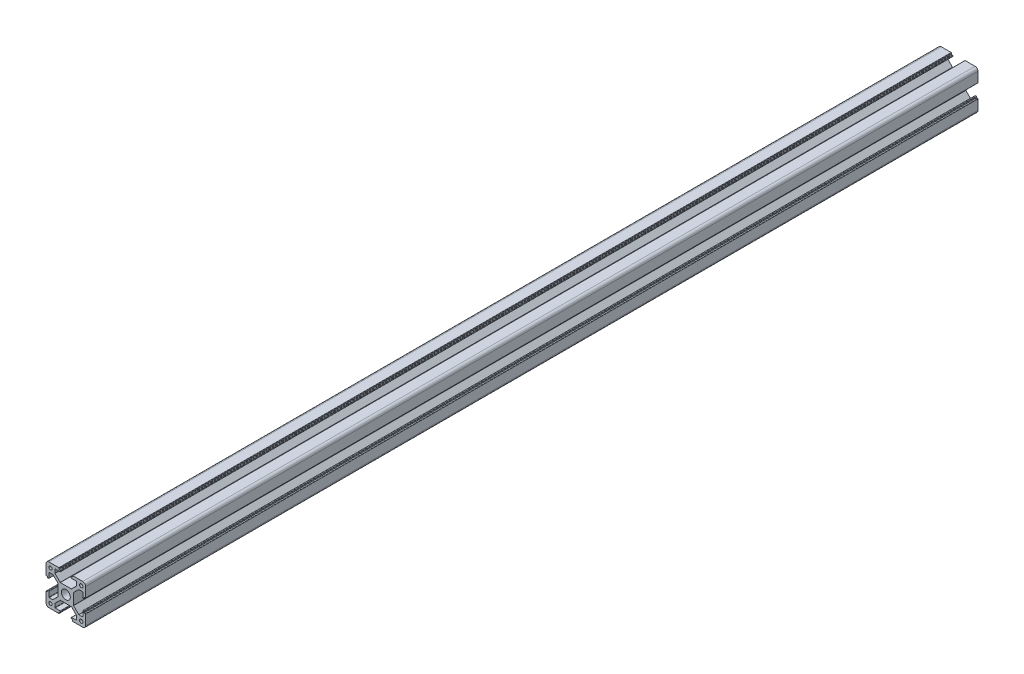
from build123d import *

# Parameters (mm, degrees)
CROQUIS1_R              = 1.25
CROQUIS1_R_2            = 3.4
SALIENTE_EXTRUIR1_DEPTH = 675


with BuildPart() as part:
    # Croquis1 → Saliente-Extruir1 (new body)
    with BuildSketch(Plane.XY):
        with BuildLine():
            Line((-4.161522369, 5.8), (4.161522369, 5.8))
            ThreePointArc((4.161522369, 5.8), (4.238059055, 5.815224093), (4.302943725, 5.858578644))
            Line((4.302943725, 5.858578644), (8.191421356, 9.747056275))
            ThreePointArc((8.191421356, 9.747056275), (8.234775907, 9.811940945), (8.25, 9.888477631))
            Line((8.25, 9.888477631), (8.25, 12.6))
            ThreePointArc((8.25, 12.6), (8.191421356, 12.741421356), (8.05, 12.8))
            Line((8.05, 12.8), (4.3, 12.8))
            ThreePointArc((4.3, 12.8), (4.158578644, 12.858578644), (4.1, 13))
            Line((4.1, 13), (4.1, 13.7))
            ThreePointArc((4.1, 13.7), (4.158578644, 13.841421356), (4.3, 13.9))
            Line((4.3, 13.9), (4.9, 13.9))
            ThreePointArc((4.9, 13.9), (5.041421356, 13.958578644), (5.1, 14.1))
            Line((5.1, 14.1), (5.1, 14.8))
            ThreePointArc((5.1, 14.8), (5.158578644, 14.941421356), (5.3, 15))
            Line((5.3, 15), (12.8, 15))
            ThreePointArc((12.8, 15), (14.355634919, 14.355634919), (15, 12.8))
            Line((15, 12.8), (15, 5.3))
            ThreePointArc((15, 5.3), (14.941421356, 5.158578644), (14.8, 5.1))
            Line((14.8, 5.1), (13.9, 5.1))
            Line((13.9, 5.1), (13.9, 4.3))
            ThreePointArc((13.9, 4.3), (13.841421356, 4.158578644), (13.7, 4.1))
            Line((13.7, 4.1), (13, 4.1))
            ThreePointArc((13, 4.1), (12.858578644, 4.158578644), (12.8, 4.3))
            Line((12.8, 4.3), (12.8, 8.05))
            ThreePointArc((12.8, 8.05), (12.741421356, 8.191421356), (12.6, 8.25))
            Line((12.6, 8.25), (9.888477631, 8.25))
            ThreePointArc((9.888477631, 8.25), (9.811940945, 8.234775907), (9.747056275, 8.191421356))
            Line((9.747056275, 8.191421356), (5.858578644, 4.302943725))
            ThreePointArc((5.858578644, 4.302943725), (5.815224093, 4.238059055), (5.8, 4.161522369))
            Line((5.8, 4.161522369), (5.8, -4.161522369))
            ThreePointArc((5.8, -4.161522369), (5.815224093, -4.238059055), (5.858578644, -4.302943725))
            Line((5.858578644, -4.302943725), (9.747056275, -8.191421356))
            ThreePointArc((9.747056275, -8.191421356), (9.811940945, -8.234775907), (9.888477631, -8.25))
            Line((9.888477631, -8.25), (12.6, -8.25))
            ThreePointArc((12.6, -8.25), (12.741421356, -8.191421356), (12.8, -8.05))
            Line((12.8, -8.05), (12.8, -4.3))
            ThreePointArc((12.8, -4.3), (12.858578644, -4.158578644), (13, -4.1))
            Line((13, -4.1), (13.7, -4.1))
            ThreePointArc((13.7, -4.1), (13.841421356, -4.158578644), (13.9, -4.3))
            Line((13.9, -4.3), (13.9, -5.1))
            Line((13.9, -5.1), (14.8, -5.1))
            ThreePointArc((14.8, -5.1), (14.941421356, -5.158578644), (15, -5.3))
            Line((15, -5.3), (15, -12.8))
            ThreePointArc((15, -12.8), (14.355634919, -14.355634919), (12.8, -15))
            Line((12.8, -15), (5.3, -15))
            ThreePointArc((5.3, -15), (5.158578644, -14.941421356), (5.1, -14.8))
            Line((5.1, -14.8), (5.1, -14.1))
            ThreePointArc((5.1, -14.1), (5.041421356, -13.958578644), (4.9, -13.9))
            Line((4.9, -13.9), (4.3, -13.9))
            ThreePointArc((4.3, -13.9), (4.158578644, -13.841421356), (4.1, -13.7))
            Line((4.1, -13.7), (4.1, -13))
            ThreePointArc((4.1, -13), (4.158578644, -12.858578644), (4.3, -12.8))
            Line((4.3, -12.8), (8.05, -12.8))
            ThreePointArc((8.05, -12.8), (8.191421356, -12.741421356), (8.25, -12.6))
            Line((8.25, -12.6), (8.25, -9.888477631))
            ThreePointArc((8.25, -9.888477631), (8.234775907, -9.811940945), (8.191421356, -9.747056275))
            Line((8.191421356, -9.747056275), (4.302943725, -5.858578644))
            ThreePointArc((4.302943725, -5.858578644), (4.238059055, -5.815224093), (4.161522369, -5.8))
            Line((4.161522369, -5.8), (-4.161522369, -5.8))
            ThreePointArc((-4.161522369, -5.8), (-4.238059055, -5.815224093), (-4.302943725, -5.858578644))
            Line((-4.302943725, -5.858578644), (-8.191421356, -9.747056275))
            ThreePointArc((-8.191421356, -9.747056275), (-8.234775907, -9.811940945), (-8.25, -9.888477631))
            Line((-8.25, -9.888477631), (-8.25, -12.6))
            ThreePointArc((-8.25, -12.6), (-8.191421356, -12.741421356), (-8.05, -12.8))
            Line((-8.05, -12.8), (-4.3, -12.8))
            ThreePointArc((-4.3, -12.8), (-4.158578644, -12.858578644), (-4.1, -13))
            Line((-4.1, -13), (-4.1, -13.7))
            ThreePointArc((-4.1, -13.7), (-4.158578644, -13.841421356), (-4.3, -13.9))
            Line((-4.3, -13.9), (-4.9, -13.9))
            ThreePointArc((-4.9, -13.9), (-5.041421356, -13.958578644), (-5.1, -14.1))
            Line((-5.1, -14.1), (-5.1, -14.8))
            ThreePointArc((-5.1, -14.8), (-5.158578644, -14.941421356), (-5.3, -15))
            Line((-5.3, -15), (-12.8, -15))
            ThreePointArc((-12.8, -15), (-14.355634919, -14.355634919), (-15, -12.8))
            Line((-15, -12.8), (-15, -5.3))
            ThreePointArc((-15, -5.3), (-14.941421356, -5.158578644), (-14.8, -5.1))
            Line((-14.8, -5.1), (-13.9, -5.1))
            Line((-13.9, -5.1), (-13.9, -4.3))
            ThreePointArc((-13.9, -4.3), (-13.841421356, -4.158578644), (-13.7, -4.1))
            Line((-13.7, -4.1), (-13, -4.1))
            ThreePointArc((-13, -4.1), (-12.858578644, -4.158578644), (-12.8, -4.3))
            Line((-12.8, -4.3), (-12.8, -8.05))
            ThreePointArc((-12.8, -8.05), (-12.741421356, -8.191421356), (-12.6, -8.25))
            Line((-12.6, -8.25), (-9.888477631, -8.25))
            ThreePointArc((-9.888477631, -8.25), (-9.811940945, -8.234775907), (-9.747056275, -8.191421356))
            Line((-9.747056275, -8.191421356), (-5.858578644, -4.302943725))
            ThreePointArc((-5.858578644, -4.302943725), (-5.815224093, -4.238059055), (-5.8, -4.161522369))
            Line((-5.8, -4.161522369), (-5.8, 4.161522369))
            ThreePointArc((-5.8, 4.161522369), (-5.815224093, 4.238059055), (-5.858578644, 4.302943725))
            Line((-5.858578644, 4.302943725), (-9.747056275, 8.191421356))
            ThreePointArc((-9.747056275, 8.191421356), (-9.811940945, 8.234775907), (-9.888477631, 8.25))
            Line((-9.888477631, 8.25), (-12.6, 8.25))
            ThreePointArc((-12.6, 8.25), (-12.741421356, 8.191421356), (-12.8, 8.05))
            Line((-12.8, 8.05), (-12.8, 4.3))
            ThreePointArc((-12.8, 4.3), (-12.858578644, 4.158578644), (-13, 4.1))
            Line((-13, 4.1), (-13.7, 4.1))
            ThreePointArc((-13.7, 4.1), (-13.841421356, 4.158578644), (-13.9, 4.3))
            Line((-13.9, 4.3), (-13.9, 5.1))
            Line((-13.9, 5.1), (-14.8, 5.1))
            ThreePointArc((-14.8, 5.1), (-14.941421356, 5.158578644), (-15, 5.3))
            Line((-15, 5.3), (-15, 12.8))
            ThreePointArc((-15, 12.8), (-14.355634919, 14.355634919), (-12.8, 15))
            Line((-12.8, 15), (-5.3, 15))
            ThreePointArc((-5.3, 15), (-5.158578644, 14.941421356), (-5.1, 14.8))
            Line((-5.1, 14.8), (-5.1, 14.1))
            ThreePointArc((-5.1, 14.1), (-5.041421356, 13.958578644), (-4.9, 13.9))
            Line((-4.9, 13.9), (-4.3, 13.9))
            ThreePointArc((-4.3, 13.9), (-4.158578644, 13.841421356), (-4.1, 13.7))
            Line((-4.1, 13.7), (-4.1, 13))
            ThreePointArc((-4.1, 13), (-4.158578644, 12.858578644), (-4.3, 12.8))
            Line((-4.3, 12.8), (-8.05, 12.8))
            ThreePointArc((-8.05, 12.8), (-8.191421356, 12.741421356), (-8.25, 12.6))
            Line((-8.25, 12.6), (-8.25, 9.888477631))
            ThreePointArc((-8.25, 9.888477631), (-8.234775907, 9.811940945), (-8.191421356, 9.747056275))
            Line((-8.191421356, 9.747056275), (-4.302943725, 5.858578644))
            ThreePointArc((-4.302943725, 5.858578644), (-4.238059055, 5.815224093), (-4.161522369, 5.8))
        make_face()
        with Locations((11.625, 11.625)):
            Circle(CROQUIS1_R, mode=Mode.SUBTRACT)
        with Locations((11.625, -11.625)):
            Circle(CROQUIS1_R, mode=Mode.SUBTRACT)
        with Locations((-11.625, -11.625)):
            Circle(CROQUIS1_R, mode=Mode.SUBTRACT)
        with Locations((-11.625, 11.625)):
            Circle(CROQUIS1_R, mode=Mode.SUBTRACT)
        Circle(CROQUIS1_R_2, mode=Mode.SUBTRACT)
    extrude(amount=SALIENTE_EXTRUIR1_DEPTH)


solid = part.part
